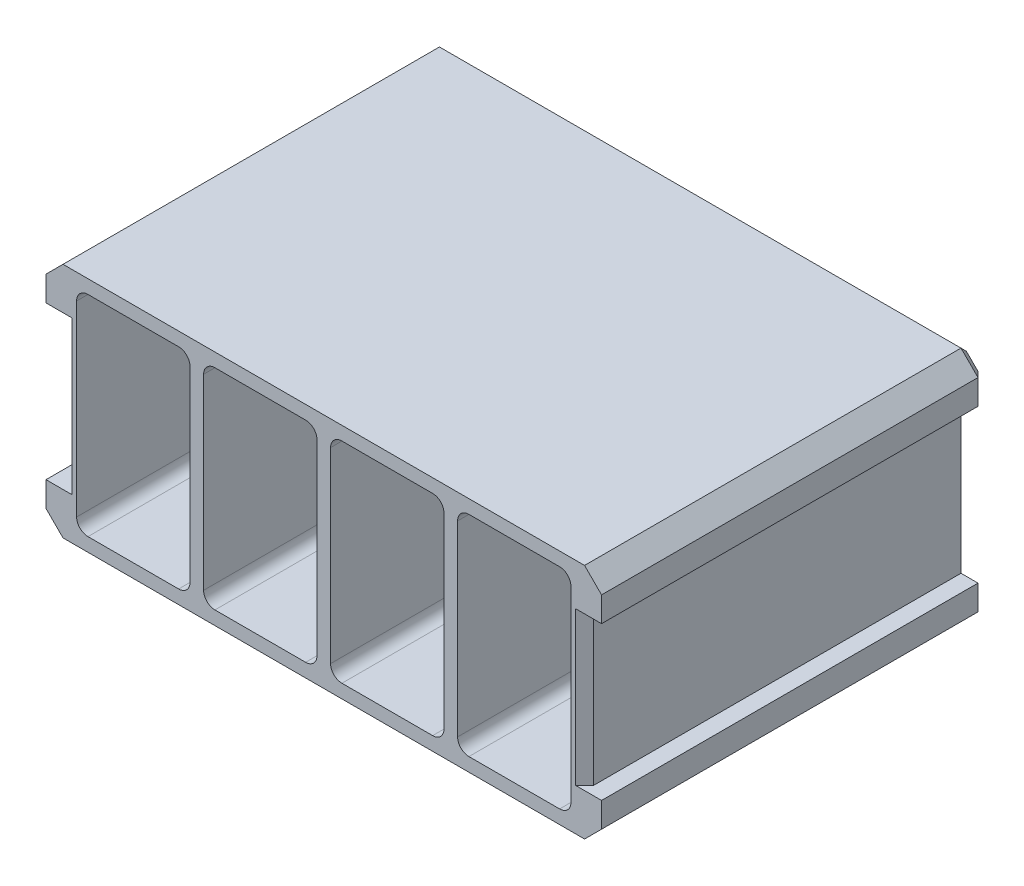
from build123d import *

# Parameters (mm, degrees)
SKETCH1_W           = 92
SKETCH1_H           = 41.8
SKETCH1_W_2         = 20
SKETCH1_H_2         = 37
BOSS_EXTRUDE1_DEPTH = 65
SKETCH2_W           = 92
SKETCH2_H           = 41.8
BOSS_EXTRUDE2_DEPTH = 3
BOSS_EXTRUDE3_DEPTH = 68
CHAMFER4_SIZE       = 1.6
SKETCH3_R           = 7.5
CUT_EXTRUDE1_DEPTH  = 4
FILLET1_R           = 2
FILLET2_R           = 2
CHAMFER5_SIZE       = 1.6


with BuildPart() as part:
    # Sketch1 → Boss-Extrude1 (new body)
    with BuildSketch(Plane.XY):
        with Locations((33.6, 0)):
            Rectangle(SKETCH1_W, SKETCH1_H)
        with Locations((22.4, 0)):
            Rectangle(SKETCH1_W_2, SKETCH1_H_2, mode=Mode.SUBTRACT)
        Rectangle(SKETCH1_W_2, SKETCH1_H_2, mode=Mode.SUBTRACT)
        with Locations((44.8, 0)):
            Rectangle(SKETCH1_W_2, SKETCH1_H_2, mode=Mode.SUBTRACT)
        with Locations((67.2, 0)):
            Rectangle(SKETCH1_W_2, SKETCH1_H_2, mode=Mode.SUBTRACT)
    extrude(amount=BOSS_EXTRUDE1_DEPTH)

    # Sketch2 → Boss-Extrude2 (add)
    with BuildSketch(Plane(origin=(0, 0, 0), x_dir=(-1, 0, 0), z_dir=(0, 0, -1))):
        with Locations((-33.6, 0)):
            Rectangle(SKETCH2_W, SKETCH2_H)
    extrude(amount=BOSS_EXTRUDE2_DEPTH)

    # Sketch4 → Boss-Extrude3 (add)
    with BuildSketch(Plane(origin=(0, 0, -3), x_dir=(-1, 0, 0), z_dir=(0, 0, -1))):
        Polygon((-79.6, 20.9), (-79.6, 13.5), (-82.6, 13.5), (-82.6, 17.9), align=None)
        Polygon((-82.6, -13.5), (-82.6, -17.9), (-79.6, -20.9), (-79.6, -13.5), align=None)
    boss_extrude3 = extrude(amount=-BOSS_EXTRUDE3_DEPTH)

    # Mirror1: Boss-Extrude3 across plane
    add(boss_extrude3.mirror(Plane.ZY.offset(-33.6)))

    # Chamfer4
    chamfer4_edges = [part.edges().sort_by_distance(p)[0] for p in [
        (81.1, -13.5, -3),
        (82.6, -15.7, -3),
        (81.1, -19.4, -3),
        (-13.9, 19.4, -3),
        (-15.4, 15.7, -3),
        (-13.9, 13.5, -3),
        (-12.4, 0, -3),
        (-13.9, -13.5, -3),
        (-15.4, -15.7, -3),
        (-13.9, -19.4, -3),
        (33.6, 20.9, -3),
        (33.6, -20.9, -3),
        (79.6, 0, -3),
        (81.1, 19.4, -3),
        (82.6, 15.7, -3),
        (81.1, 13.5, -3),
    ]]
    chamfer(chamfer4_edges, length=CHAMFER4_SIZE)

    # Sketch3 → Cut-Extrude1 (cut, through all)
    with BuildSketch(Plane.XY):
        Circle(SKETCH3_R)
        with Locations((22.4, 0)):
            Circle(SKETCH3_R)
        with Locations((44.8, 0)):
            Circle(SKETCH3_R)
        with Locations((67.2, 0)):
            Circle(SKETCH3_R)
    extrude(amount=-CUT_EXTRUDE1_DEPTH, mode=Mode.SUBTRACT)

    # Fillet1
    fillet1_edges = [part.edges().sort_by_distance(p)[0] for p in [
        (10, -18.5, 32.5),
        (10, 18.5, 32.5),
        (-10, 18.5, 32.5),
        (-10, -18.5, 32.5),
        (32.4, 18.5, 32.5),
        (12.4, 18.5, 32.5),
        (12.4, -18.5, 32.5),
        (32.4, -18.5, 32.5),
        (54.8, 18.5, 32.5),
        (34.8, 18.5, 32.5),
        (34.8, -18.5, 32.5),
        (54.8, -18.5, 32.5),
        (77.2, 18.5, 32.5),
        (57.2, 18.5, 32.5),
        (57.2, -18.5, 32.5),
        (77.2, -18.5, 32.5),
    ]]
    fillet(fillet1_edges, radius=FILLET1_R)

    # Fillet2
    fillet2_edges = [part.edges().sort_by_distance(p)[0] for p in [
        (67.2, -18.5, 0),
        (77.2, 0, 0),
        (67.2, 18.5, 0),
        (57.2, 0, 0),
        (76.614213562, 17.914213562, 0),
        (57.785786438, 17.914213562, 0),
        (57.785786438, -17.914213562, 0),
        (76.614213562, -17.914213562, 0),
        (44.8, -18.5, 0),
        (54.8, 0, 0),
        (44.8, 18.5, 0),
        (34.8, 0, 0),
        (54.214213562, 17.914213562, 0),
        (35.385786438, 17.914213562, 0),
        (35.385786438, -17.914213562, 0),
        (54.214213562, -17.914213562, 0),
        (22.4, -18.5, 0),
        (32.4, 0, 0),
        (22.4, 18.5, 0),
        (12.4, 0, 0),
        (12.985786438, 17.914213562, 0),
        (31.814213562, 17.914213562, 0),
        (12.985786438, -17.914213562, 0),
        (31.814213562, -17.914213562, 0),
        (0, -18.5, 0),
        (10, 0, 0),
        (0, 18.5, 0),
        (-10, 0, 0),
        (-9.414213562, 17.914213562, 0),
        (9.414213562, 17.914213562, 0),
        (-9.414213562, -17.914213562, 0),
        (9.414213562, -17.914213562, 0),
    ]]
    fillet(fillet2_edges, radius=FILLET2_R)

    # Chamfer5
    chamfer5_edges = [part.edges().sort_by_distance(p)[0] for p in [
        (79.6, 0, 65),
        (-12.4, 0, 65),
    ]]
    chamfer(chamfer5_edges, length=CHAMFER5_SIZE)


solid = part.part
